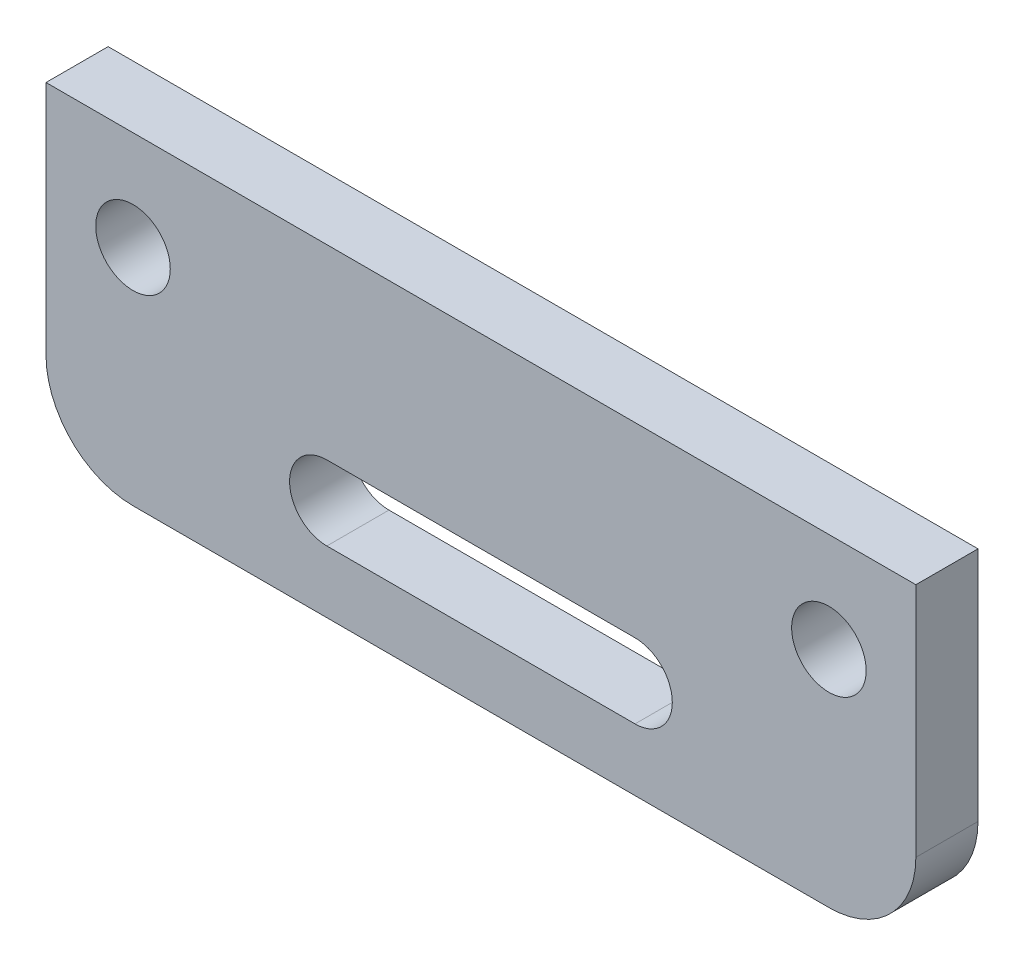
from build123d import *

# Parameters (mm, degrees)
SKETCH1_R           = 1
SKETCH1_R_2         = 1.5
SKETCH1_R_3         = 2
SKETCH1_W           = 23
SKETCH1_H           = 12
BOSS_EXTRUDE1_DEPTH = 2.5
FILLET1_R           = 3.5
SKETCH2_W           = 57.93350489
SKETCH2_H           = 33.625772429
CUT_EXTRUDE1_DEPTH  = 10


with BuildPart() as part:
    # Sketch1 → Boss-Extrude1 (new body)
    with BuildSketch(Plane.XY):
        with BuildLine():
            Line((-17.5, 9), (-17.5, -19))
            Line((-17.5, -19), (17.5, -19))
            Line((17.5, -19), (17.5, 9))
            ThreePointArc((17.5, 9), (0, 26), (-17.5, 9))
        make_face()
        with Locations((-14, 0)):
            Circle(SKETCH1_R, mode=Mode.SUBTRACT)
        with Locations((-14, -10)):
            Circle(SKETCH1_R_2, mode=Mode.SUBTRACT)
        with Locations((-8.5, 16)):
            Circle(SKETCH1_R_3, mode=Mode.SUBTRACT)
        with Locations((14, -10)):
            Circle(SKETCH1_R_2, mode=Mode.SUBTRACT)
        with Locations((14, 0)):
            Circle(SKETCH1_R, mode=Mode.SUBTRACT)
        with Locations((8.5, 16)):
            Circle(SKETCH1_R_3, mode=Mode.SUBTRACT)
        Rectangle(SKETCH1_W, SKETCH1_H, mode=Mode.SUBTRACT)
        with BuildLine():
            Line((-6.2, -13.5), (6.2, -13.5))
            ThreePointArc((6.2, -13.5), (7.7, -15), (6.2, -16.5))
            Line((6.2, -16.5), (-6.2, -16.5))
            ThreePointArc((-6.2, -16.5), (-7.7, -15), (-6.2, -13.5))
        make_face(mode=Mode.SUBTRACT)
    extrude(amount=BOSS_EXTRUDE1_DEPTH)

    # Fillet1
    fillet1_edges = [part.edges().sort_by_distance(p)[0] for p in [
        (17.5, -19, 1.25),
        (-17.5, -19, 1.25),
    ]]
    fillet(fillet1_edges, radius=FILLET1_R)

    # Sketch2 → Cut-Extrude1 (cut)
    with BuildSketch(Plane.XY.offset(2.5)):
        with Locations((-1.18759747, 10.812886215)):
            Rectangle(SKETCH2_W, SKETCH2_H)
    extrude(amount=-CUT_EXTRUDE1_DEPTH, mode=Mode.SUBTRACT)


solid = part.part
